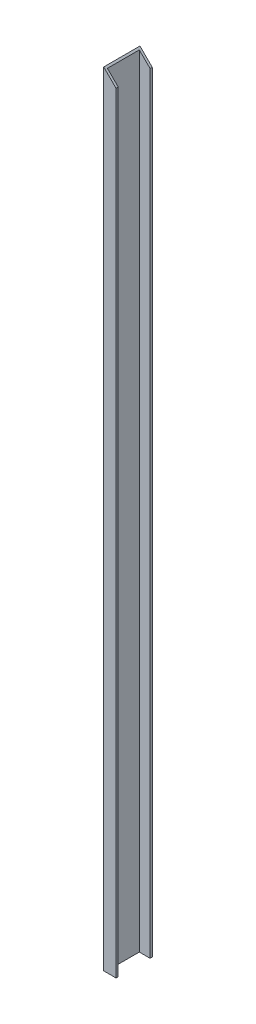
from build123d import *

# Parameters (mm, degrees)
BOSS_EXTRUDE2_DEPTH = 2743.2
CUT_EXTRUDE1_DEPTH  = 128


with BuildPart() as part:
    # Sketch3 → Boss-Extrude2 (new body)
    with BuildSketch(Plane(origin=(0, 0, 0), x_dir=(1, 0, 0), z_dir=(0, 1, 0))):
        Polygon((0, 0), (43.18, 0), (43.18, 7.62), (5.330413857, 7.62), (5.330413857, 119.38), (43.18, 119.38), (43.18, 127), (0, 127), align=None)
    extrude(amount=BOSS_EXTRUDE2_DEPTH)

    # Sketch5 → Cut-Extrude1 (cut, through all)
    with BuildSketch(Plane.XY):
        Polygon((0, 2743.2), (43.18, 2700.02), (43.18, 2743.2), align=None)
    extrude(amount=-CUT_EXTRUDE1_DEPTH, mode=Mode.SUBTRACT)


solid = part.part
